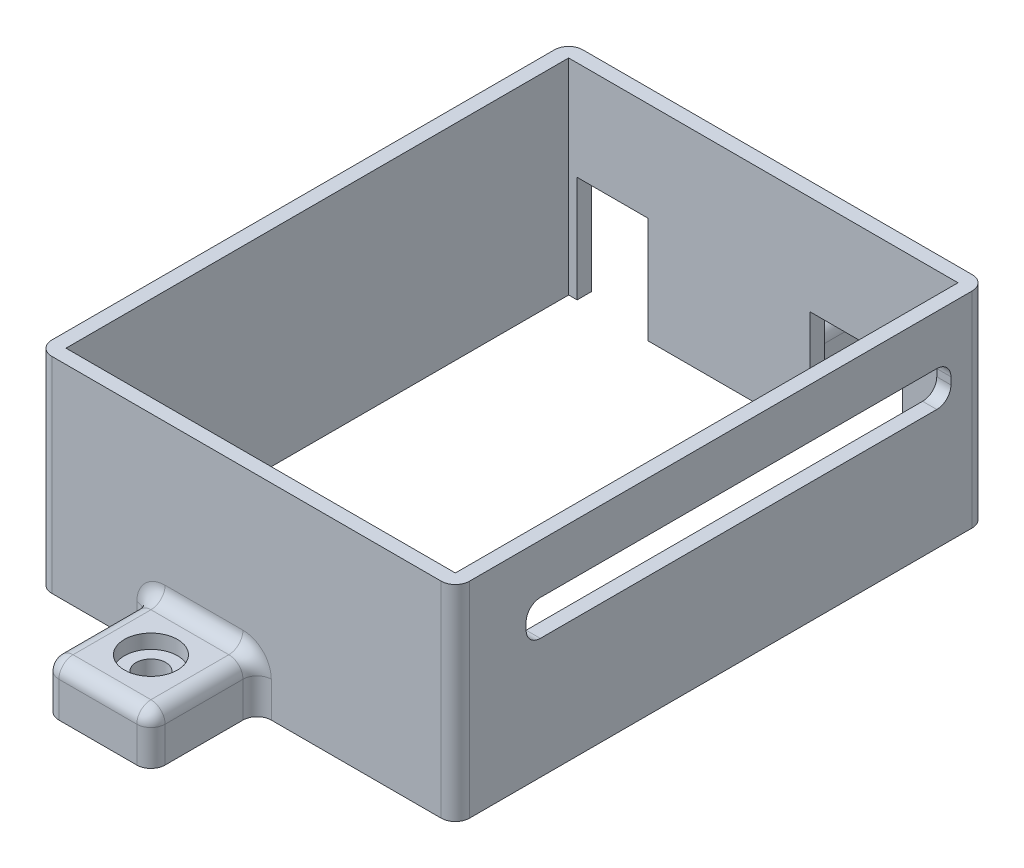
from build123d import *

# Parameters (mm, degrees)
SKETCH1_W            = 55
SKETCH1_H            = 71
BOSS_EXTRUDE1_DEPTH  = 29
SKETCH2_W            = 13
SKETCH2_H            = 15
SKETCH2_W_2          = 10
CUT_EXTRUDE1_DEPTH   = 27
CUT_EXTRUDE2_DEPTH   = 27
SKETCH4_W            = 15
SKETCH4_H            = 15
BOSS_EXTRUDE2_DEPTH  = 7
FILLET1_R            = 2
SKETCH5_R            = 2.1
CUT_EXTRUDE3_DEPTH   = 15
SKETCH6_R            = 3.75
CUT_EXTRUDE4_DEPTH   = 2
FILLET1_OF_MIRROR2_R = 2
FILLET2_R            = 2


with BuildPart() as part:
    # Sketch1 → Boss-Extrude1 (new body)
    with BuildSketch(Plane(origin=(0, 0, 0), x_dir=(1, 0, 0), z_dir=(0, 1, 0))):
        with BuildLine():
            Line((-27.5, 37.5), (27.5, 37.5))
            ThreePointArc((27.5, 37.5), (28.914213562, 36.914213562), (29.5, 35.5))
            Line((29.5, 35.5), (29.5, -35.5))
            ThreePointArc((29.5, -35.5), (28.914213562, -36.914213562), (27.5, -37.5))
            Line((27.5, -37.5), (-27.5, -37.5))
            ThreePointArc((-27.5, -37.5), (-28.914213562, -36.914213562), (-29.5, -35.5))
            Line((-29.5, -35.5), (-29.5, 35.5))
            ThreePointArc((-29.5, 35.5), (-28.914213562, 36.914213562), (-27.5, 37.5))
        make_face()
        Rectangle(SKETCH1_W, SKETCH1_H, mode=Mode.SUBTRACT)
    extrude(amount=BOSS_EXTRUDE1_DEPTH)

    # Sketch2 → Cut-Extrude1 (cut)
    with BuildSketch(Plane(origin=(0, 0, -37.5), x_dir=(-1, 0, 0), z_dir=(0, 0, -1))):
        with Locations((-13.12561668, 7.5)):
            Rectangle(SKETCH2_W, SKETCH2_H)
        with Locations((21.3, 7.5)):
            Rectangle(SKETCH2_W_2, SKETCH2_H)
    extrude(amount=-CUT_EXTRUDE1_DEPTH, mode=Mode.SUBTRACT)

    # Sketch3 → Cut-Extrude2 (cut)
    with BuildSketch(Plane(origin=(29.5, 0, 0), x_dir=(0, 0, -1), z_dir=(1, 0, 0))):
        with BuildLine():
            Line((-25.5, 22), (30.5, 22))
            ThreePointArc((30.5, 22), (31.914213562, 21.414213562), (32.5, 20))
            Line((32.5, 20), (32.5, 19))
            ThreePointArc((32.5, 19), (31.914213562, 17.585786438), (30.5, 17))
            Line((30.5, 17), (-25.5, 17))
            ThreePointArc((-25.5, 17), (-26.914213562, 17.585786438), (-27.5, 19))
            Line((-27.5, 19), (-27.5, 20))
            ThreePointArc((-27.5, 20), (-26.914213562, 21.414213562), (-25.5, 22))
        make_face()
    extrude(amount=-CUT_EXTRUDE2_DEPTH, mode=Mode.SUBTRACT)

    # Sketch4 → Boss-Extrude2 (add)
    with BuildSketch(Plane.XZ):
        with Locations((-6, 45)):
            Rectangle(SKETCH4_W, SKETCH4_H)
    boss_extrude2 = extrude(amount=-BOSS_EXTRUDE2_DEPTH)

    # Fillet1
    fillet1_edges = [part.edges().sort_by_distance(p)[0] for p in [
        (-13.5, 7, 45),
        (-6, 7, 52.5),
        (-13.5, 3.5, 52.5),
        (1.5, 7, 45),
        (1.5, 3.5, 52.5),
    ]]
    fillet(fillet1_edges, radius=FILLET1_R)

    # Sketch5 → Cut-Extrude3 (cut)
    with BuildSketch(Plane(origin=(0, 7, 0), x_dir=(1, 0, 0), z_dir=(0, 1, 0))):
        with Locations(Location((-6, -45, 0), (0, 0, 270))):  # turned: the seam where the file's is
            Circle(SKETCH5_R)
    cut_extrude3 = extrude(amount=-CUT_EXTRUDE3_DEPTH, mode=Mode.SUBTRACT)

    # Sketch6 → Cut-Extrude4 (cut)
    with BuildSketch(Plane(origin=(0, 7, 0), x_dir=(1, 0, 0), z_dir=(0, 1, 0))):
        with Locations(Location((-6, -45, 0), (0, 0, 270))):  # turned: the seam where the file's is
            Circle(SKETCH6_R)
    cut_extrude4 = extrude(amount=-CUT_EXTRUDE4_DEPTH, mode=Mode.SUBTRACT)

    # Mirror2: Boss-Extrude2, Cut-Extrude3, Cut-Extrude4 across plane
    add(boss_extrude2.mirror(Plane.XY))
    add(cut_extrude3.mirror(Plane.XY), mode=Mode.SUBTRACT)
    add(cut_extrude4.mirror(Plane.XY), mode=Mode.SUBTRACT)

    # Fillet1 of Mirror2
    fillet1_of_mirror2_edges = [part.edges().sort_by_distance(p)[0] for p in [
        (-13.5, 7, -45),
        (-6, 7, -52.5),
        (-13.5, 3.5, -52.5),
        (1.5, 7, -45),
        (1.5, 3.5, -52.5),
    ]]
    fillet(fillet1_of_mirror2_edges, radius=FILLET1_OF_MIRROR2_R)

    # Fillet2
    fillet2_edges = [part.edges().sort_by_distance(p)[0] for p in [
        (1.5, 2.5, 37.5),
        (-6, 7, 37.5),
        (-13.5, 2.5, 37.5),
        (0.914213562, 6.414213562, 37.5),
        (-12.914213562, 6.414213562, 37.5),
        (-6, 7, -37.5),
        (1.5, 2.5, -37.5),
        (-13.5, 2.5, -37.5),
        (0.914213562, 6.414213562, -37.5),
        (-12.914213562, 6.414213562, -37.5),
    ]]
    fillet(fillet2_edges, radius=FILLET2_R)


solid = part.part
